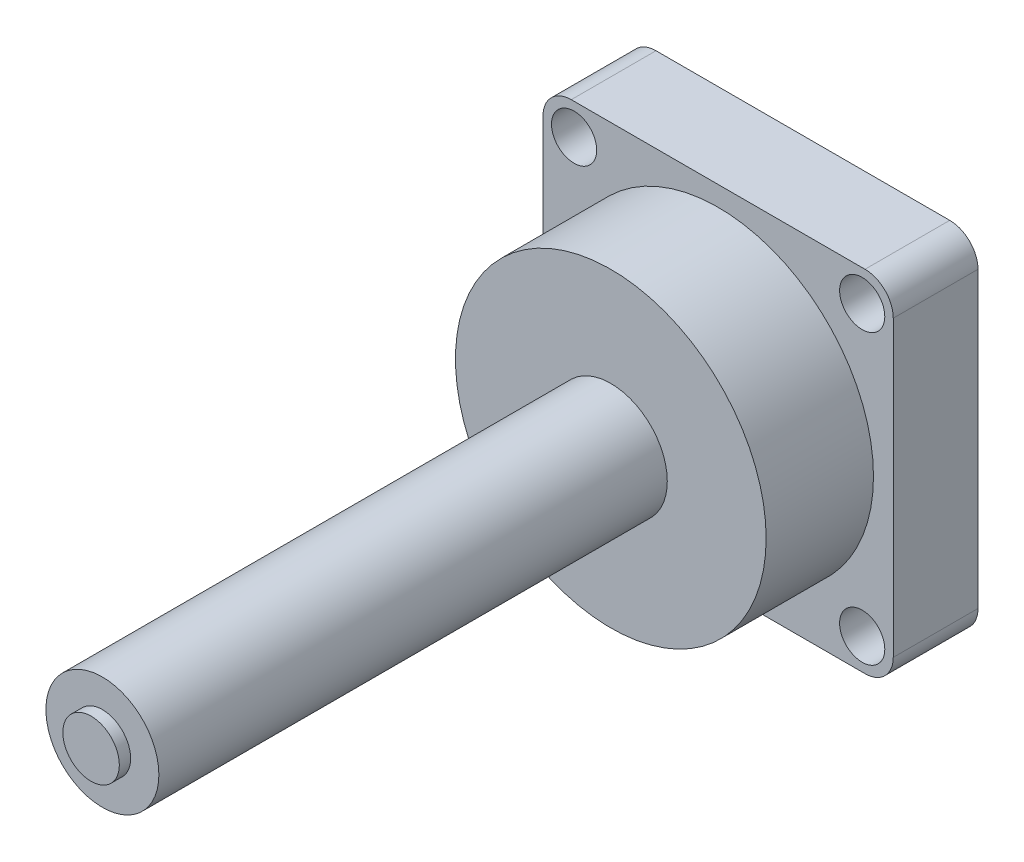
from build123d import *

# Parameters (mm, degrees)
SKETCH1_R           = 27.5
SKETCH1_R_2         = 4
BOSS_EXTRUDE1_DEPTH = 15
SKETCH1_3_R         = 27.5
SKETCH1_3_R_2       = 10
BOSS_EXTRUDE2_DEPTH = 34
SKETCH1_4_R         = 10
BOSS_EXTRUDE3_DEPTH = 124
BOSS_EXTRUDE4_START = 124
SKETCH1_5_R         = 5
BOSS_EXTRUDE4_DEPTH = 2


with BuildPart() as part:
    # Sketch1 → Boss-Extrude1 (new body)
    with BuildSketch(Plane.XY):
        with BuildLine():
            Line((-26, 31), (26, 31))
            ThreePointArc((26, 31), (29.535533906, 29.535533906), (31, 26))
            Line((31, 26), (31, -26))
            ThreePointArc((31, -26), (29.535533906, -29.535533906), (26, -31))
            Line((26, -31), (-26, -31))
            ThreePointArc((-26, -31), (-29.535533906, -29.535533906), (-31, -26))
            Line((-31, -26), (-31, 26))
            ThreePointArc((-31, 26), (-29.535533906, 29.535533906), (-26, 31))
        make_face()
        Circle(SKETCH1_R, mode=Mode.SUBTRACT)
        with Locations((-25.5, 25.5)):
            Circle(SKETCH1_R_2, mode=Mode.SUBTRACT)
        with Locations((25.5, 25.5)):
            Circle(SKETCH1_R_2, mode=Mode.SUBTRACT)
        with Locations((-25.5, -25.5)):
            Circle(SKETCH1_R_2, mode=Mode.SUBTRACT)
        with Locations((25.5, -25.5)):
            Circle(SKETCH1_R_2, mode=Mode.SUBTRACT)
    extrude(amount=BOSS_EXTRUDE1_DEPTH)

    # Sketch1_3 → Boss-Extrude2 (add)
    with BuildSketch(Plane.XY):
        Circle(SKETCH1_3_R)
        Circle(SKETCH1_3_R_2, mode=Mode.SUBTRACT)
    extrude(amount=BOSS_EXTRUDE2_DEPTH)

    # Sketch1_4 → Boss-Extrude3 (add)
    with BuildSketch(Plane.XY):
        Circle(SKETCH1_4_R)
    extrude(amount=BOSS_EXTRUDE3_DEPTH)

    # Sketch1_5 → Boss-Extrude4 (add)
    with BuildSketch(Plane.XY.offset(BOSS_EXTRUDE4_START)):
        Circle(SKETCH1_5_R)
    extrude(amount=BOSS_EXTRUDE4_DEPTH)


solid = part.part
